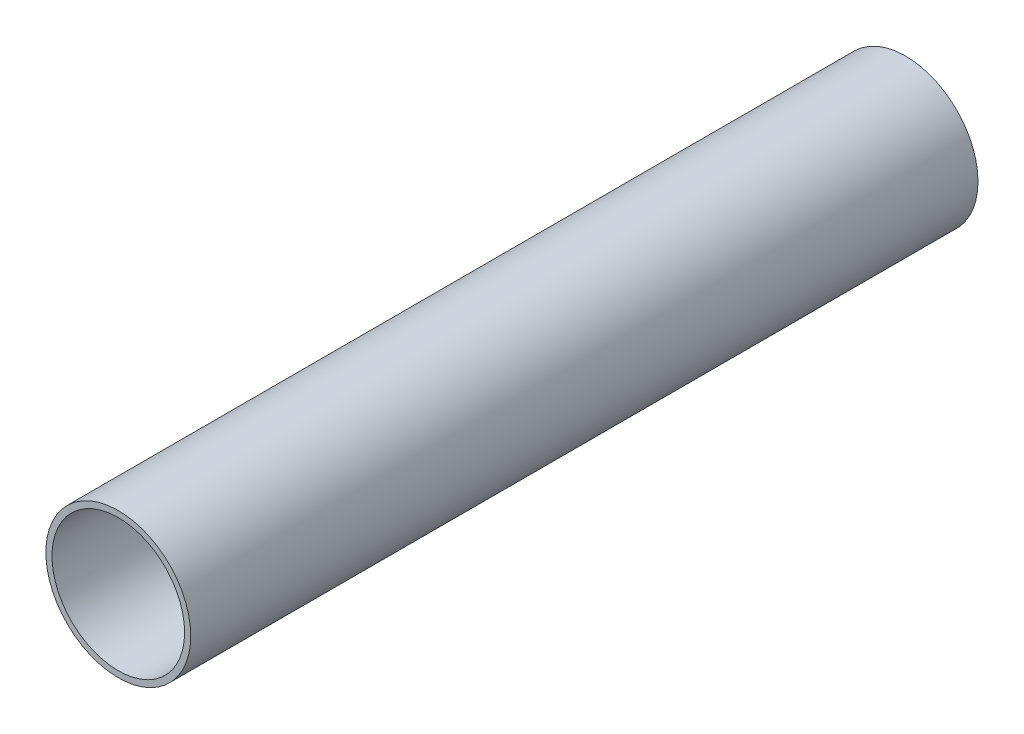
from build123d import *

# Parameters (mm, degrees)
SKETCH1_R           = 84.1375
SKETCH1_R_2         = 77.0255
EXTRUDE_THIN1_DEPTH = 457.2


with BuildPart() as part:
    # Sketch1 → Extrude-Thin1 (new body, symmetric)
    with BuildSketch(Plane.XY):
        Circle(SKETCH1_R)
        Circle(SKETCH1_R_2, mode=Mode.SUBTRACT)
    extrude(amount=EXTRUDE_THIN1_DEPTH, both=True)


solid = part.part
